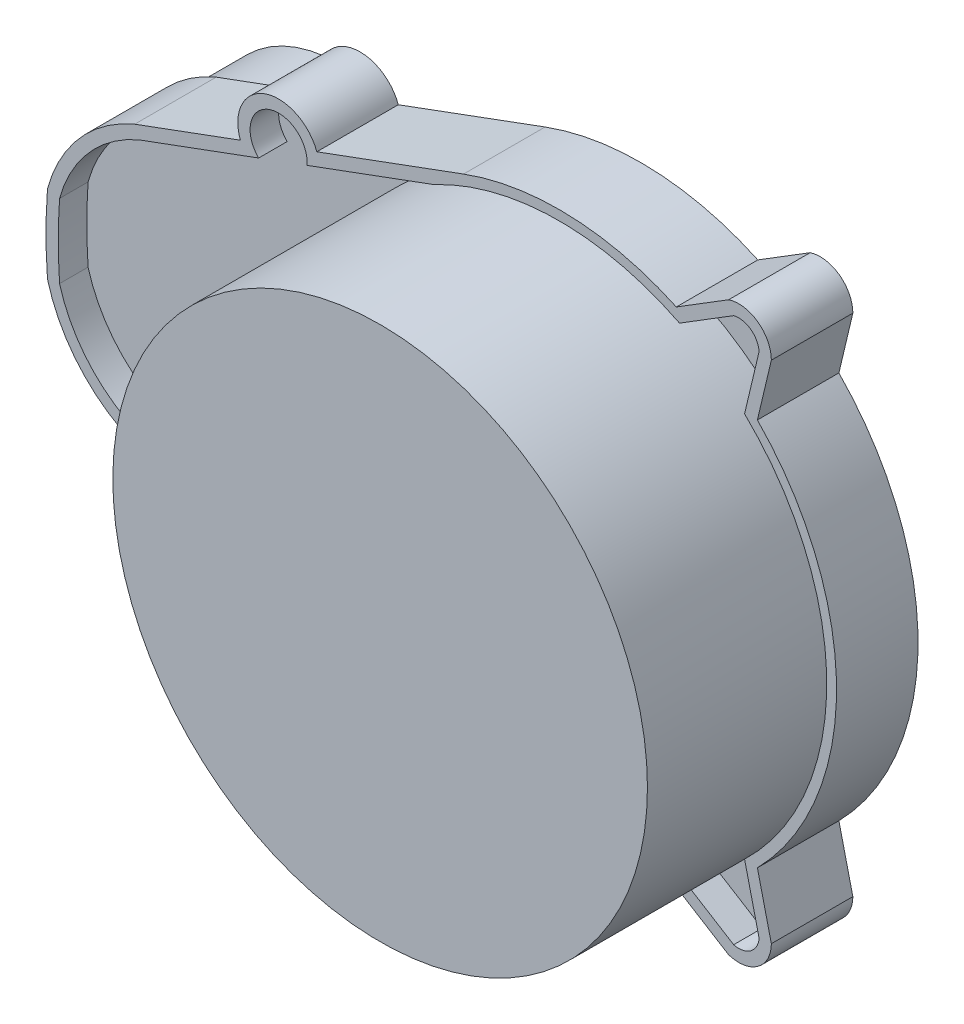
from build123d import *

# Parameters (mm, degrees)
ESQUISSE1_R             = 1.6
BOSS_EXTRU_1_DEPTH      = 10
ESQUISSE2_R             = 32.8
BOSS_EXTRU_2_DEPTH      = 22
ENL_V_MAT_EXTRU_1_DEPTH = 3.5
BOSS_EXTRU_3_REACH      = 12
ESQUISSE5_R             = 16
BOSS_EXTRU_4_DEPTH      = 10


with BuildPart() as part:
    # Esquisse1 → Boss.-Extru.1 (new body)
    with BuildSketch(Plane.XY):
        with BuildLine():
            ThreePointArc((-52.114163482, -17.022112424), (-58.887228209, -12.14530881), (-62.818181851, -4.782889184))
            ThreePointArc((-62.818181851, -4.782889184), (-63, 0), (-62.818181851, 4.782889184))
            ThreePointArc((-62.818181851, 4.782889184), (-58.887228209, 12.14530881), (-52.114163482, 17.022112424))
            Line((-52.114163482, 17.022112424), (-39.149984877, 21.802247897))
            ThreePointArc((-39.149984877, 21.802247897), (-36.188478781, 28.223266636), (-29.767460042, 25.26176054))
            Line((-29.767460042, 25.26176054), (-11.762342986, 31.900584438))
            ThreePointArc((-11.762342986, 31.900584438), (1.39665257, 33.97130203), (14.341260705, 30.827394333))
            Line((14.341260705, 30.827394333), (20.756023105, 34.801647207))
            ThreePointArc((20.756023105, 34.801647207), (24.347774736, 34.238511045), (26, 31))
            Line((26, 31), (24.288429708, 23.792271483))
            ThreePointArc((24.288429708, 23.792271483), (34, 0), (24.288429708, -23.792271483))
            Line((24.288429708, -23.792271483), (26, -31))
            ThreePointArc((26, -31), (24.347774736, -34.238511045), (20.756023105, -34.801647207))
            Line((20.756023105, -34.801647207), (14.341260705, -30.827394333))
            ThreePointArc((14.341260705, -30.827394333), (1.39665257, -33.97130203), (-11.762342986, -31.900584438))
            Line((-11.762342986, -31.900584438), (-29.767460042, -25.26176054))
            ThreePointArc((-29.767460042, -25.26176054), (-36.188478781, -28.223266636), (-39.149984877, -21.802247897))
            Line((-39.149984877, -21.802247897), (-52.114163482, -17.022112424))
        make_face()
        with Locations((-35, -25)):
            Circle(ESQUISSE1_R, mode=Mode.SUBTRACT)
        with Locations((22, 31)):
            Circle(ESQUISSE1_R, mode=Mode.SUBTRACT)
        with Locations((-35, 25)):
            Circle(ESQUISSE1_R, mode=Mode.SUBTRACT)
        with Locations((22, -31)):
            Circle(ESQUISSE1_R, mode=Mode.SUBTRACT)
    extrude(amount=BOSS_EXTRU_1_DEPTH)

    # Esquisse2 → Boss.-Extru.2 (add)
    with BuildSketch(Plane.XY.offset(10)):
        Circle(ESQUISSE2_R)
    extrude(amount=BOSS_EXTRU_2_DEPTH)

    # Esquisse3 → Enlèv. mat.-Extru.1 (cut)
    with BuildSketch(Plane.XY.offset(10)):
        with BuildLine():
            Line((-51.564604514, -15.626028317), (-36.906810431, -21.030631539))
            ThreePointArc((-36.906810431, -21.030631539), (-35.669551885, -26.815887911), (-30.972780695, -23.218619448))
            Line((-30.972780695, -23.218619448), (-11.24341609, -30.493205713))
            ThreePointArc((-11.24341609, -30.493205713), (1.736287169, -32.453586965), (14.43273391, -29.119515653))
            Line((14.43273391, -29.119515653), (21.375089208, -33.420637623))
            ThreePointArc((21.375089208, -33.420637623), (23.468804453, -33.02302088), (24.495170617, -31.155317718))
            Line((24.495170617, -31.155317718), (22.63500045, -23.321808563))
            ThreePointArc((22.63500045, -23.321808563), (32.5, 0), (22.63500045, 23.321808563))
            Line((22.63500045, 23.321808563), (24.495170617, 31.155317718))
            ThreePointArc((24.495170617, 31.155317718), (23.468804453, 33.02302088), (21.375089208, 33.420637623))
            Line((21.375089208, 33.420637623), (14.43273391, 29.119515653))
            ThreePointArc((14.43273391, 29.119515653), (1.736287169, 32.453586965), (-11.24341609, 30.493205713))
            Line((-11.24341609, 30.493205713), (-30.972780695, 23.218619448))
            ThreePointArc((-30.972780695, 23.218619448), (-35.669551885, 26.815887911), (-36.906810431, 21.030631539))
            Line((-36.906810431, 21.030631539), (-51.564604514, 15.626028317))
            ThreePointArc((-51.564604514, 15.626028317), (-57.722932582, 11.197936413), (-61.33314674, 4.527152633))
            ThreePointArc((-61.33314674, 4.527152633), (-61.5, 0), (-61.33314674, -4.527152633))
            ThreePointArc((-61.33314674, -4.527152633), (-57.722932582, -11.197936413), (-51.564604514, -15.626028317))
        make_face()
    extrude(amount=-ENL_V_MAT_EXTRU_1_DEPTH, mode=Mode.SUBTRACT)

    # Esquisse4 → Boss.-Extru.3 (add, up to next)
    with BuildSketch(Plane(origin=(0, 0, 10), x_dir=(-1, 0, 0), z_dir=(0, 0, -1)), mode=Mode.PRIVATE) as boss_extru_3_sk1:
        with BuildLine():
            Line((-22.715550233, 23.661018101), (-22.63500045, 23.321808563))
            ThreePointArc((-22.63500045, 23.321808563), (-32.5, 0), (-22.63500045, -23.321808563))
            Line((-22.63500045, -23.321808563), (-22.715550233, -23.661018101))
            ThreePointArc((-22.715550233, -23.661018101), (-18.935479047, -26.78222607), (-14.732448894, -29.305203456))
            Line((-14.732448894, -29.305203456), (-14.43273391, -29.119515653))
            ThreePointArc((-14.43273391, -29.119515653), (-1.736287169, -32.453586965), (11.24341609, -30.493205713))
            Line((11.24341609, -30.493205713), (15.396177122, -28.962004938))
            ThreePointArc((15.396177122, -28.962004938), (32.8, 0), (15.396177122, 28.962004938))
            Line((15.396177122, 28.962004938), (11.24341609, 30.493205713))
            ThreePointArc((11.24341609, 30.493205713), (-1.736287169, 32.453586965), (-14.43273391, 29.119515653))
            Line((-14.43273391, 29.119515653), (-14.732448894, 29.305203456))
            ThreePointArc((-14.732448894, 29.305203456), (-18.935479047, 26.78222607), (-22.715550233, 23.661018101))
        make_face()
    boss_extru_3_tool1 = extrude(boss_extru_3_sk1.sketch, amount=BOSS_EXTRU_3_REACH, mode=Mode.PRIVATE) - part.part
    add(boss_extru_3_tool1.solids().sort_by_distance((-0.139045, 0, 10))[0])

    # Esquisse5 → Boss.-Extru.4 (add)
    with BuildSketch(Plane(origin=(0, 0, 0), x_dir=(-1, 0, 0), z_dir=(0, 0, -1))):
        with Locations((47, 0)):
            Circle(ESQUISSE5_R)
    extrude(amount=BOSS_EXTRU_4_DEPTH)


solid = part.part
